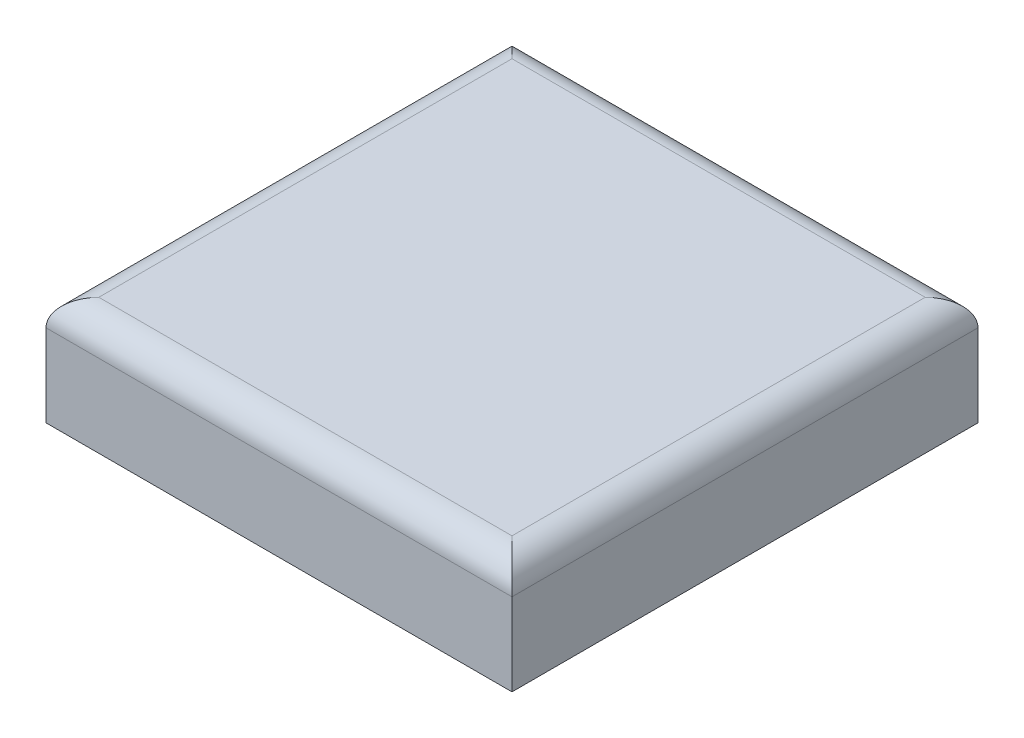
from build123d import *

# Parameters (mm, degrees)
CROQUIS1_W              = 3000
CROQUIS1_H              = 3000
SALIENTE_EXTRUIR1_DEPTH = 700
REDONDEO1_R             = 170


with BuildPart() as part:
    # Croquis1 → Saliente-Extruir1 (new body)
    with BuildSketch(Plane(origin=(0, 0, 0), x_dir=(1, 0, 0), z_dir=(0, 1, 0))):
        with Locations((1500, 1500)):
            Rectangle(CROQUIS1_W, CROQUIS1_H)
    extrude(amount=SALIENTE_EXTRUIR1_DEPTH)

    # Redondeo1
    redondeo1_edges = [part.edges().sort_by_distance(p)[0] for p in [
        (3000, 700, -1500),
        (1500, 700, -3000),
        (0, 700, -1500),
        (1500, 700, 0),
    ]]
    fillet(redondeo1_edges, radius=REDONDEO1_R)


solid = part.part
